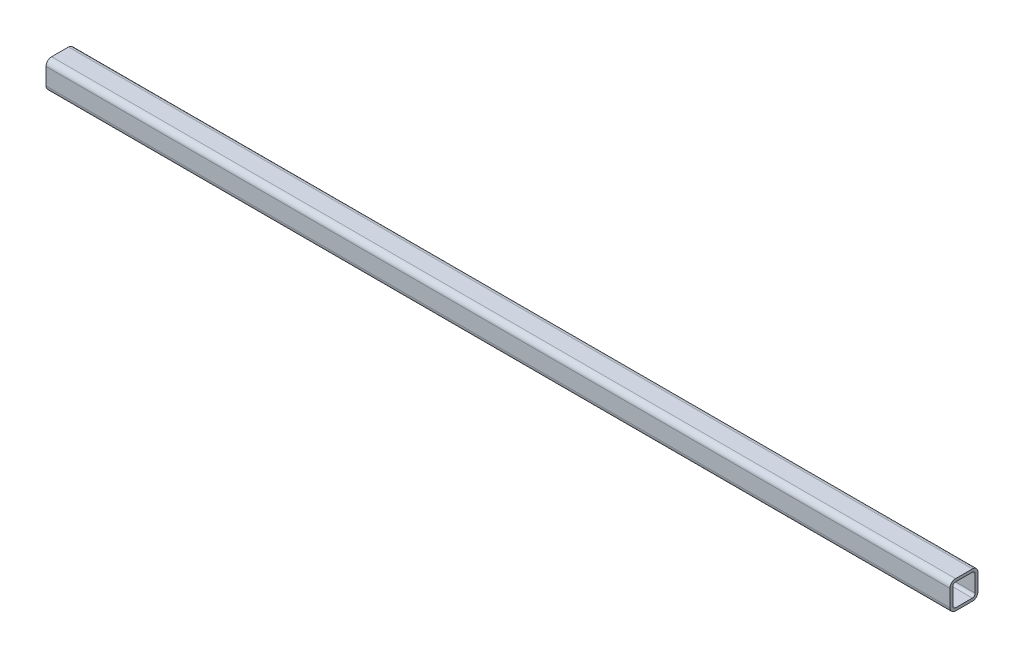
from build123d import *

# Parameters (mm, degrees)
SQUARE_TUBE_20_X_20_X_2_1_DEPTH = 645


with BuildPart() as part:
    # Sketch11 → Square tube 20 X 20 X 2(1) (new body)
    with BuildSketch(Plane(origin=(-322.5, 0, 0), x_dir=(0, 0, -1), z_dir=(1, 0, 0))):
        with BuildLine():
            Line((-6, -10), (6, -10))
            ThreePointArc((6, -10), (8.828427125, -8.828427125), (10, -6))
            Line((10, -6), (10, 6))
            ThreePointArc((10, 6), (8.828427125, 8.828427125), (6, 10))
            Line((6, 10), (-6, 10))
            ThreePointArc((-6, 10), (-8.828427125, 8.828427125), (-10, 6))
            Line((-10, 6), (-10, -6))
            ThreePointArc((-10, -6), (-8.828427125, -8.828427125), (-6, -10))
        make_face()
        with BuildLine():
            Line((-6, -8), (6, -8))
            ThreePointArc((6, -8), (7.414213562, -7.414213562), (8, -6))
            Line((8, -6), (8, 6))
            ThreePointArc((8, 6), (7.414213562, 7.414213562), (6, 8))
            Line((6, 8), (-6, 8))
            ThreePointArc((-6, 8), (-7.414213562, 7.414213562), (-8, 6))
            Line((-8, 6), (-8, -6))
            ThreePointArc((-8, -6), (-7.414213562, -7.414213562), (-6, -8))
        make_face(mode=Mode.SUBTRACT)
    extrude(amount=SQUARE_TUBE_20_X_20_X_2_1_DEPTH)


solid = part.part
